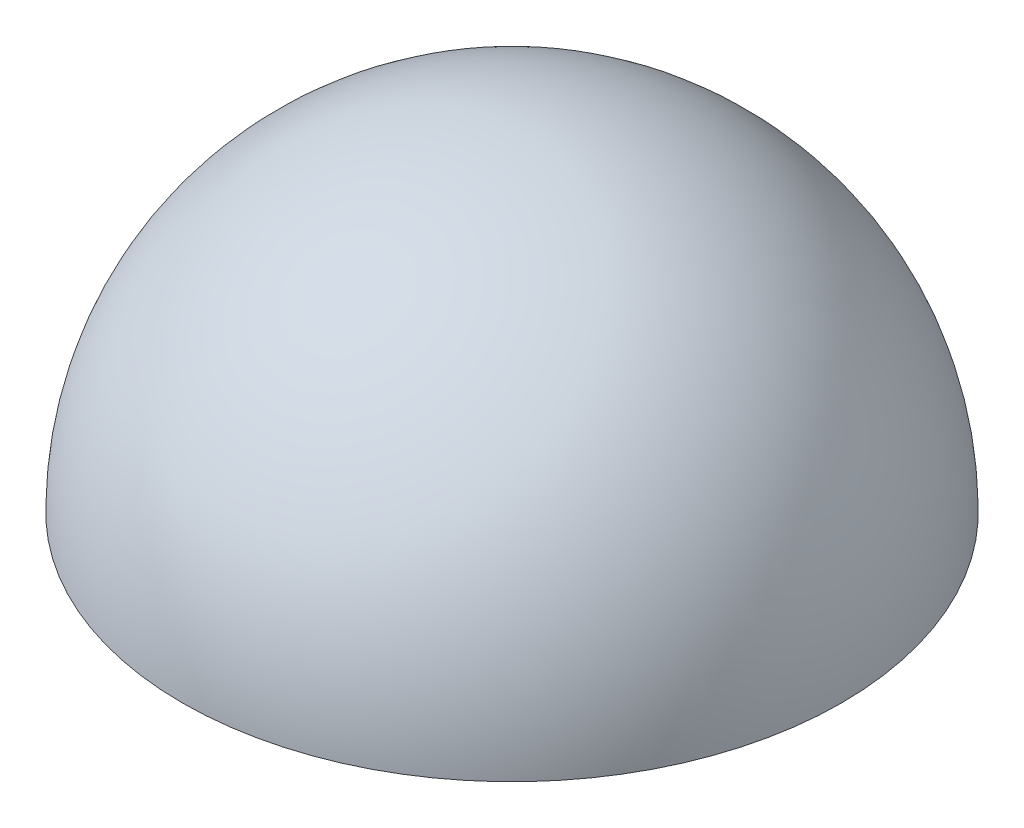
from build123d import *


with BuildPart() as part:
    # Sketch1 → Revolve1 (revolve)
    with BuildSketch(Plane.XY):
        with BuildLine():
            Line((0, 8.4), (0, 9))
            ThreePointArc((0, 9), (6.363961031, 6.363961031), (9, 0))
            Line((9, 0), (8.4, 0))
            ThreePointArc((8.4, 0), (5.939696962, 5.939696962), (0, 8.4))
        make_face()
    revolve(axis=Axis((0, 8.3, 0), (0, -1, 0)))


with BuildPart() as body_2:
    # Sketch2 → Revolve2 (revolve)
    with BuildSketch(Plane.XY):
        with BuildLine():
            Line((0, 8.3), (0, 0))
            Line((0, 0), (8.3, 0))
            ThreePointArc((8.3, 0), (5.868986284, 5.868986284), (0, 8.3))
        make_face()
    revolve(axis=Axis((0, 8.3, 0), (0, -1, 0)))


solid = Compound([part.part, body_2.part])
